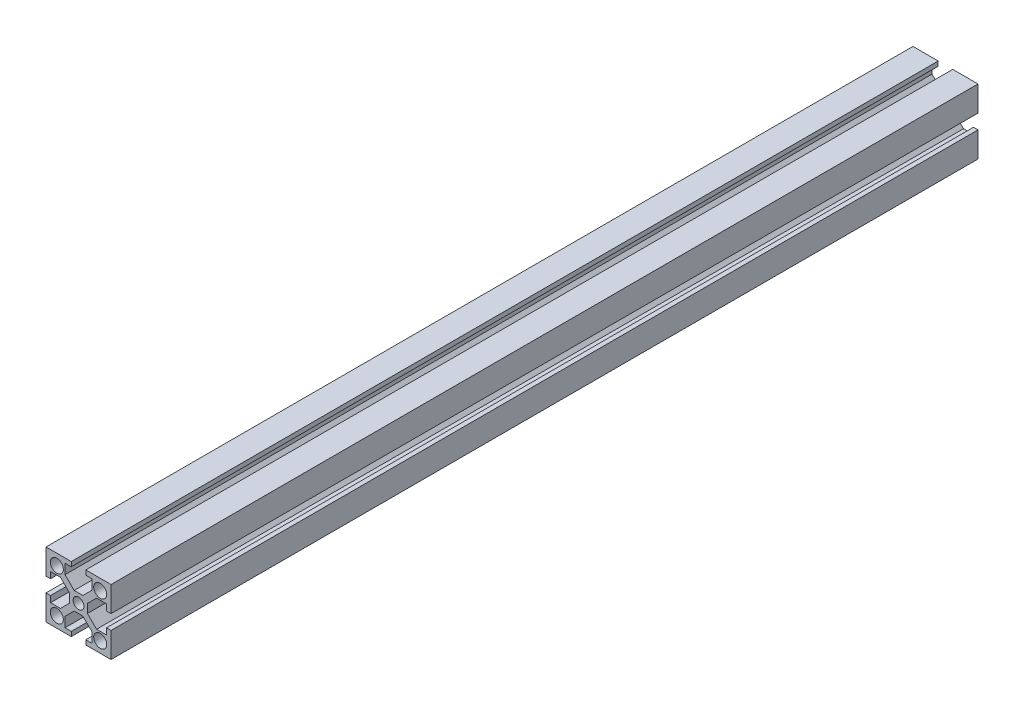
from build123d import *

# Parameters (mm, degrees)
SKETCH1_R           = 2.5
SKETCH1_R_2         = 3
BOSS_EXTRUDE1_DEPTH = 400


with BuildPart() as part:
    # Sketch1 → Boss-Extrude1 (new body)
    with BuildSketch(Plane.XY):
        Polygon((-15, 15), (-3.35, 15), (-3.35, 12.901975832), (-6.216494866, 12.901975832), (-6.216494866, 8.323198212), (-2.018681454, 4.1253848), (2.018681454, 4.1253848), (6.216494866, 8.323198212), (6.216494866, 12.901975832), (3.35, 12.901975832), (3.35, 15), (15, 15), (15, 3.35), (12.901975832, 3.35), (12.901975832, 6.216494866), (8.323198212, 6.216494866), (4.1253848, 2.018681454), (4.1253848, -2.018681454), (8.323198212, -6.216494866), (12.901975832, -6.216494866), (12.901975832, -3.35), (15, -3.35), (15, -15), (3.35, -15), (3.35, -12.901975832), (6.216494866, -12.901975832), (6.216494866, -8.323198212), (2.018681454, -4.1253848), (-2.018681454, -4.1253848), (-6.216494866, -8.323198212), (-6.216494866, -12.901975832), (-3.35, -12.901975832), (-3.35, -15), (-15, -15), (-15, -3.35), (-12.901975832, -3.35), (-12.901975832, -6.216494866), (-8.323198212, -6.216494866), (-4.1253848, -2.018681454), (-4.1253848, 2.018681454), (-8.323198212, 6.216494866), (-12.901975832, 6.216494866), (-12.901975832, 3.35), (-15, 3.35), align=None)
        Circle(SKETCH1_R, mode=Mode.SUBTRACT)
        with Locations((10, 10)):
            Circle(SKETCH1_R_2, mode=Mode.SUBTRACT)
        with Locations((-10, 10)):
            Circle(SKETCH1_R_2, mode=Mode.SUBTRACT)
        with Locations((-10, -10)):
            Circle(SKETCH1_R_2, mode=Mode.SUBTRACT)
        with Locations((10, -10)):
            Circle(SKETCH1_R_2, mode=Mode.SUBTRACT)
    extrude(amount=BOSS_EXTRUDE1_DEPTH)


solid = part.part
